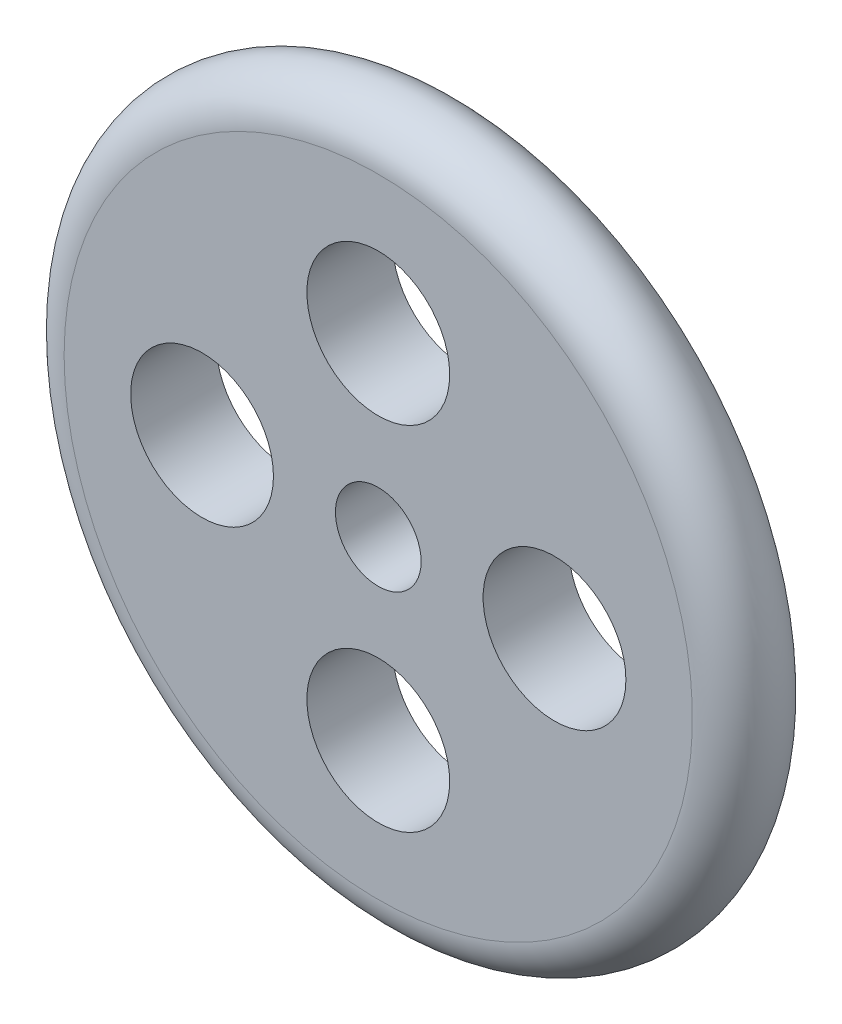
from build123d import *

# Parameters (mm, degrees)
SKETCH10_R         = 15
CUT_EXTRUDE1_DEPTH = 31
SKETCH11_R         = 25
CUT_EXTRUDE2_DEPTH = 31


with BuildPart() as part:
    # Sketch6 → Revolve3 (revolve)
    with BuildSketch(Plane(origin=(0, 0, 0), x_dir=(1, 0, 0), z_dir=(0, 1, 0))):
        with BuildLine():
            Line((-1.369e-06, 75.786874096), (109.999998631, 75.786874096))
            ThreePointArc((109.999998631, 75.786874096), (124.999998631, 60.786874096), (109.999998631, 45.786874096))
            Line((109.999998631, 45.786874096), (-1.369e-06, 45.786874096))
            Line((-1.369e-06, 45.786874096), (-1.369e-06, 75.786874096))
        make_face()
    revolve(axis=Axis((-1.369e-06, 0, -75.786874096), (0, 0, 1)))

    # Sketch10 → Cut-Extrude1 (cut, through all)
    with BuildSketch(Plane.XY.offset(-45.786874096)):
        Circle(SKETCH10_R)
    extrude(amount=-CUT_EXTRUDE1_DEPTH, mode=Mode.SUBTRACT)

    # Sketch11 → Cut-Extrude2 (cut, through all)
    with BuildSketch(Plane.XY.offset(-45.786874096)):
        with Locations((0, 61.701118812)):
            Circle(SKETCH11_R)
        with Locations((61.701118812, 0)):
            Circle(SKETCH11_R)
        with Locations((0, -61.701118812)):
            Circle(SKETCH11_R)
        with Locations((-61.701118812, 0)):
            Circle(SKETCH11_R)
    extrude(amount=-CUT_EXTRUDE2_DEPTH, mode=Mode.SUBTRACT)


solid = part.part
